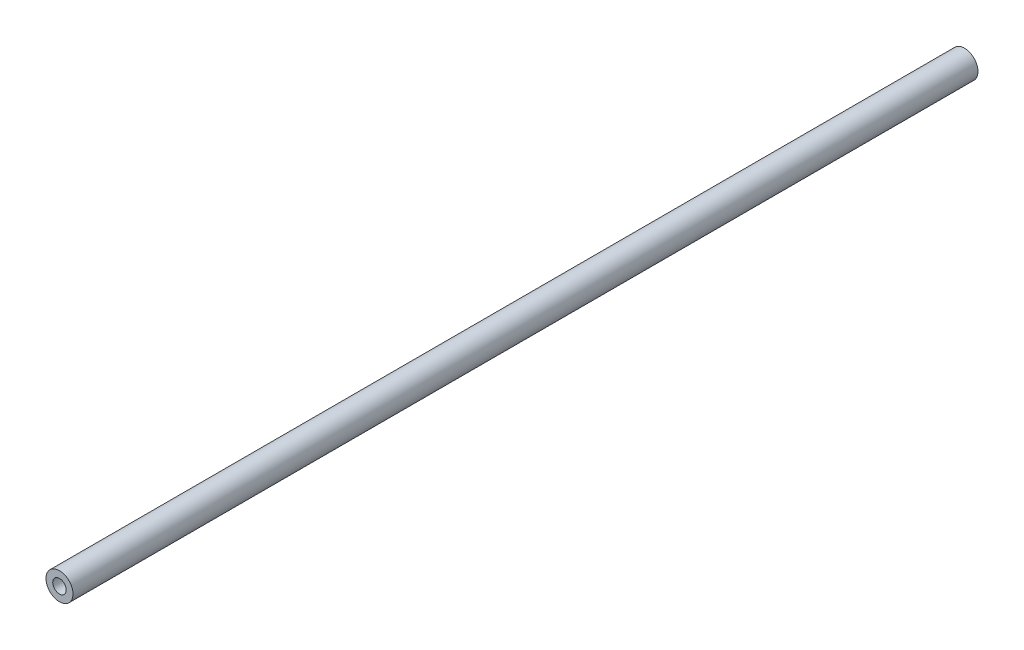
from build123d import *

# Parameters (mm, degrees)
SKIZZE1_R                       = 5
AUFSATZ_LINEAR_AUSTRAGEN1_DEPTH = 335
SKIZZE2_R                       = 2.5
SCHNITT_LINEAR_AUSTRAGEN3_DEPTH = 17
SKIZZE3_R                       = 2.5
SCHNITT_LINEAR_AUSTRAGEN4_DEPTH = 17


with BuildPart() as part:
    # Skizze1 → Aufsatz-Linear austragen1 (new body)
    with BuildSketch(Plane.XY):
        Circle(SKIZZE1_R)
    extrude(amount=AUFSATZ_LINEAR_AUSTRAGEN1_DEPTH)

    # Skizze2 → Schnitt-Linear austragen3 (cut)
    with BuildSketch(Plane.XY):
        Circle(SKIZZE2_R)
    extrude(amount=SCHNITT_LINEAR_AUSTRAGEN3_DEPTH, mode=Mode.SUBTRACT)

    # Skizze3 → Schnitt-Linear austragen4 (cut)
    with BuildSketch(Plane.XY.offset(335)):
        Circle(SKIZZE3_R)
    extrude(amount=-SCHNITT_LINEAR_AUSTRAGEN4_DEPTH, mode=Mode.SUBTRACT)


solid = part.part
